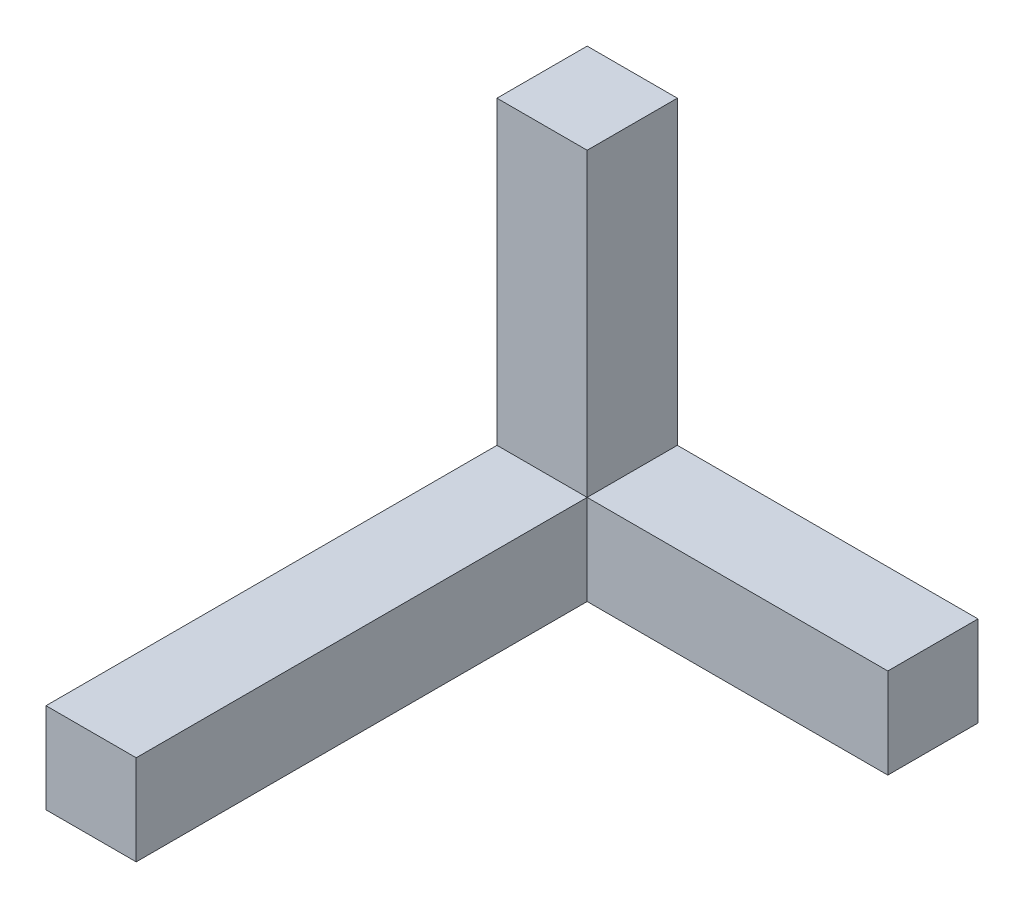
from build123d import *

# Parameters (mm, degrees)
SKETCH1_W           = 3
SKETCH1_H           = 3
BOSS_EXTRUDE2_DEPTH = 15
SKETCH2_W           = 3
SKETCH2_H           = 3
BOSS_EXTRUDE3_DEPTH = 10
SKETCH3_W           = 3
SKETCH3_H           = 3
BOSS_EXTRUDE4_DEPTH = 10
SKETCH4_W           = 3
SKETCH4_H           = 3
BOSS_EXTRUDE5_DEPTH = 15
SKETCH1_2_W         = 3
SKETCH1_2_H         = 3
CUT_EXTRUDE1_DEPTH  = 12


with BuildPart() as part:
    # Sketch1 → Boss-Extrude2 (new body)
    with BuildSketch(Plane.XY):
        Rectangle(SKETCH1_W, SKETCH1_H)
    extrude(amount=BOSS_EXTRUDE2_DEPTH)

    # Sketch2 → Boss-Extrude3 (add)
    with BuildSketch(Plane(origin=(1.5, 0, 0), x_dir=(0, 0, -1), z_dir=(1, 0, 0))):
        with Locations((-13.5, 0)):
            Rectangle(SKETCH2_W, SKETCH2_H)
    extrude(amount=BOSS_EXTRUDE3_DEPTH)

    # Sketch3 → Boss-Extrude4 (add)
    with BuildSketch(Plane(origin=(0, 1.5, 0), x_dir=(1, 0, 0), z_dir=(0, 1, 0))):
        with Locations((0, -13.5)):
            Rectangle(SKETCH3_W, SKETCH3_H)
    extrude(amount=BOSS_EXTRUDE4_DEPTH)

    # Sketch4 → Boss-Extrude5 (add)
    with BuildSketch(Plane.XY.offset(15)):
        Rectangle(SKETCH4_W, SKETCH4_H)
    extrude(amount=BOSS_EXTRUDE5_DEPTH)

    # Sketch1_2 → Cut-Extrude1 (cut)
    with BuildSketch(Plane.XY):
        Rectangle(SKETCH1_2_W, SKETCH1_2_H)
    extrude(amount=CUT_EXTRUDE1_DEPTH, mode=Mode.SUBTRACT)


solid = part.part
